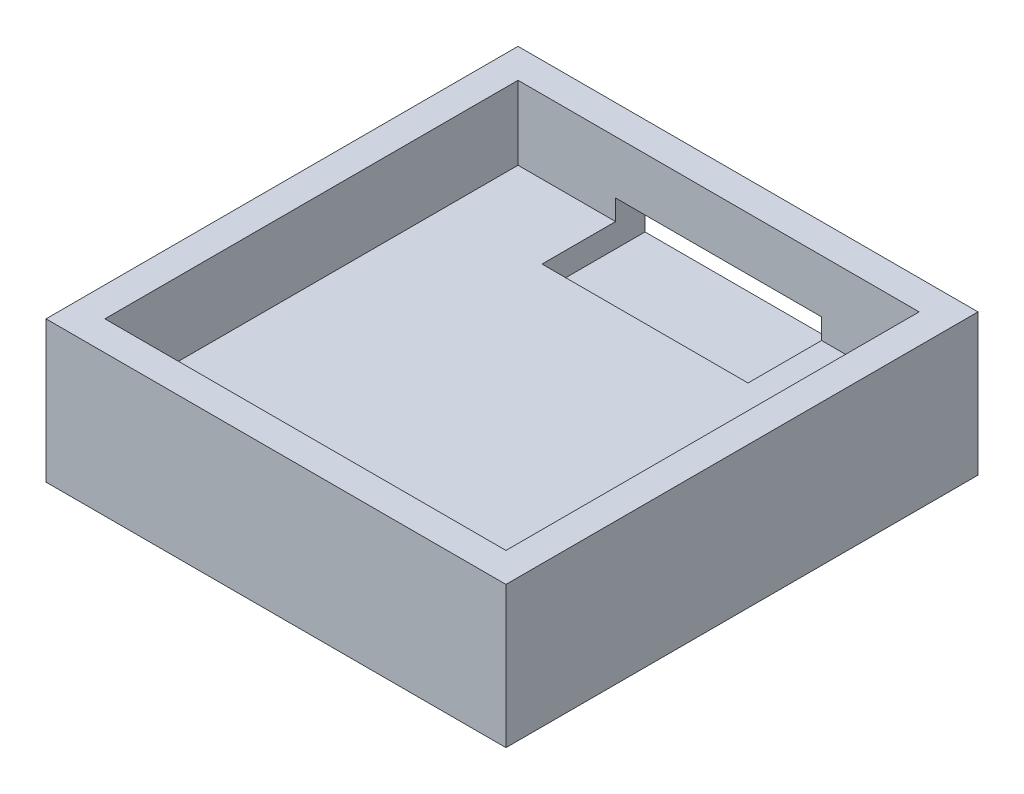
from build123d import *

# Parameters (mm, degrees)
SKETCH1_W           = 31.26
SKETCH1_H           = 32.08
BOSS_EXTRUDE2_DEPTH = 1.61
SKETCH4_W           = 31.26
SKETCH4_H           = 32.08
SKETCH4_W_2         = 27.26
SKETCH4_H_2         = 28.08
BOSS_EXTRUDE3_DEPTH = 5
SKETCH5_W           = 14
SKETCH5_H           = 5
CUT_EXTRUDE3_DEPTH  = 5
SKETCH8_W           = 14
SKETCH8_H           = 3
CUT_EXTRUDE5_DEPTH  = 5
SKETCH9_W           = 31.26
SKETCH9_H           = 32.08
BOSS_EXTRUDE4_DEPTH = 3
SKETCH10_R          = 2.5
CUT_EXTRUDE6_DEPTH  = 2


with BuildPart() as part:
    # Sketch1 → Boss-Extrude2 (new body)
    with BuildSketch(Plane(origin=(0, 0, 0), x_dir=(1, 0, 0), z_dir=(0, 1, 0))):
        with Locations((2.801725352, -6.324753521)):
            Rectangle(SKETCH1_W, SKETCH1_H)
    extrude(amount=BOSS_EXTRUDE2_DEPTH)

    # Sketch4 → Boss-Extrude3 (add)
    with BuildSketch(Plane(origin=(0, 1.61, 0), x_dir=(1, 0, 0), z_dir=(0, 1, 0))):
        with Locations((2.801725352, -6.324753521)):
            Rectangle(SKETCH4_W, SKETCH4_H)
        with Locations((2.801725352, -6.324753521)):
            Rectangle(SKETCH4_W_2, SKETCH4_H_2, mode=Mode.SUBTRACT)
    extrude(amount=BOSS_EXTRUDE3_DEPTH)

    # Sketch5 → Cut-Extrude3 (cut)
    with BuildSketch(Plane(origin=(0, 1.61, 0), x_dir=(1, 0, 0), z_dir=(0, 1, 0))):
        with Locations((2.801725352, 5.215246479)):
            Rectangle(SKETCH5_W, SKETCH5_H)
    extrude(amount=-CUT_EXTRUDE3_DEPTH, mode=Mode.SUBTRACT)

    # Sketch8 → Cut-Extrude5 (cut)
    with BuildSketch(Plane(origin=(0, 0, -9.715246479), x_dir=(-1, 0, 0), z_dir=(0, 0, -1))):
        with Locations((-2.801725352, 1.5)):
            Rectangle(SKETCH8_W, SKETCH8_H)
    extrude(amount=-CUT_EXTRUDE5_DEPTH, mode=Mode.SUBTRACT)

    # Sketch9 → Boss-Extrude4 (add)
    with BuildSketch(Plane.XZ):
        with Locations((2.801725352, 6.324753521)):
            Rectangle(SKETCH9_W, SKETCH9_H)
    extrude(amount=BOSS_EXTRUDE4_DEPTH)

    # Sketch10 → Cut-Extrude6 (cut)
    with BuildSketch(Plane.XZ.offset(3)):
        with Locations((2.801725352, 15.644753521)):
            Circle(SKETCH10_R)
        with Locations((11.101725352, 6.324753521)):
            Circle(SKETCH10_R)
        with Locations((-5.498274648, 6.324753521)):
            Circle(SKETCH10_R)
        with Locations((2.801725352, -2.995246479)):
            Circle(SKETCH10_R)
    extrude(amount=-CUT_EXTRUDE6_DEPTH, mode=Mode.SUBTRACT)


solid = part.part
